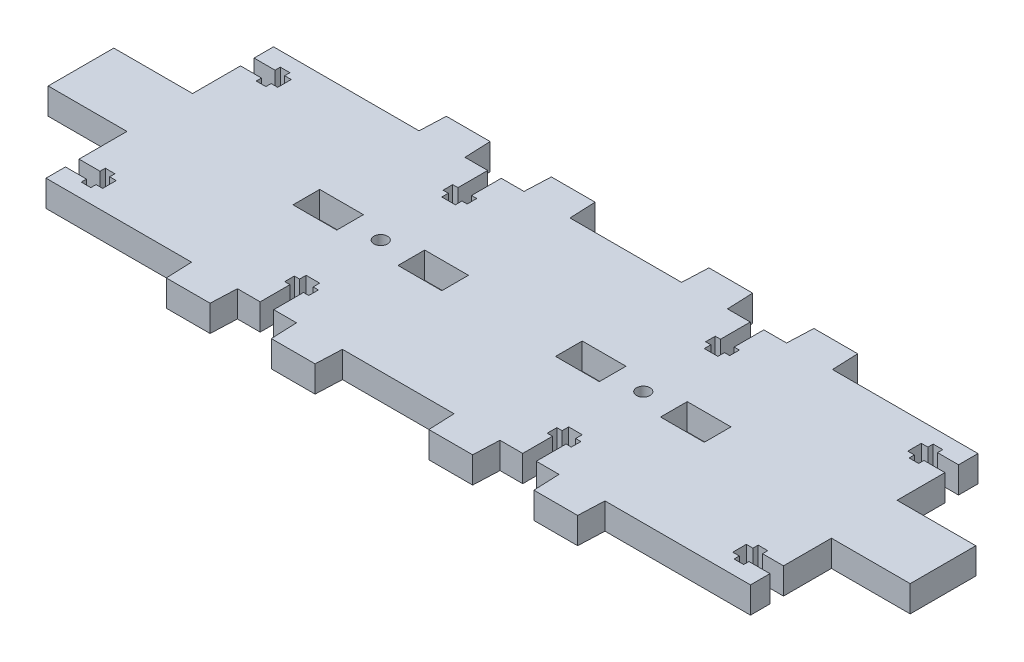
from build123d import *

# Parameters (mm, degrees)
SKETCH_1_R      = 1.55
SKETCH_1_W      = 10
SKETCH_1_H      = 6.1
EXTRUDE_1_DEPTH = 6


with BuildPart() as part:
    # Эскиз1 → Бобышка-Вытянуть1 (new body)
    with BuildSketch(Plane(origin=(0, 0, 0), x_dir=(1, 0, 0), z_dir=(0, 1, 0))):
        Polygon((10.144022003, 31.870182818), (9.894022003, 25.870182818), (-15.605977997, 25.870182818), (-15.855977997, 31.870182818), (-25.855977997, 31.870182818), (-26.105977997, 25.870182818), (-31.305977997, 25.870182818), (-31.305977997, 19.070182818), (-30.105977997, 19.070182818), (-30.105977997, 16.870182818), (-31.305977997, 16.870182818), (-31.305977997, 15.370182818), (-34.405977997, 15.370182818), (-34.405977997, 16.870182818), (-35.605977997, 16.870182818), (-35.605977997, 19.070182818), (-34.405977997, 19.070182818), (-34.405977997, 25.870182818), (-39.605977997, 25.870182818), (-39.855977997, 31.870182818), (-49.855977997, 31.870182818), (-50.105977997, 25.870182818), (-83.355977997, 25.870182818), (-83.355977997, 21.420182818), (-78.555977997, 21.420182818), (-78.555977997, 22.620182818), (-76.355977997, 22.620182818), (-76.355977997, 21.420182818), (-74.855977997, 21.420182818), (-74.855977997, 18.320182818), (-76.355977997, 18.320182818), (-76.355977997, 17.120182818), (-78.555977997, 17.120182818), (-78.555977997, 18.320182818), (-83.355977997, 18.320182818), (-83.355977997, 7.370182818), (-101.355977997, 7.370182818), (-101.355977997, -7.629817182), (-83.355977997, -7.629817182), (-83.355977997, -18.579817182), (-78.555977997, -18.579817182), (-78.555977997, -17.379817182), (-76.355977997, -17.379817182), (-76.355977997, -18.579817182), (-74.855977997, -18.579817182), (-74.855977997, -21.679817182), (-76.355977997, -21.679817182), (-76.355977997, -22.879817182), (-78.555977997, -22.879817182), (-78.555977997, -21.679817182), (-83.355977997, -21.679817182), (-83.355977997, -26.129817182), (-50.105977997, -26.129817182), (-49.855977997, -32.129817182), (-39.855977997, -32.129817182), (-39.605977997, -26.129817182), (-34.405977997, -26.129817182), (-34.405977997, -19.329817182), (-35.605977997, -19.329817182), (-35.605977997, -17.129817182), (-34.405977997, -17.129817182), (-34.405977997, -15.629817182), (-31.305977997, -15.629817182), (-31.305977997, -17.129817182), (-30.105977997, -17.129817182), (-30.105977997, -19.329817182), (-31.305977997, -19.329817182), (-31.305977997, -26.129817182), (-26.105977997, -26.129817182), (-25.855977997, -32.129817182), (-15.855977997, -32.129817182), (-15.605977997, -26.129817182), (9.894022003, -26.129817182), (10.144022003, -32.129817182), (20.144022003, -32.129817182), (20.394022003, -26.129817182), (25.594022003, -26.129817182), (25.594022003, -19.329817182), (24.394022003, -19.329817182), (24.394022003, -17.129817182), (25.594022003, -17.129817182), (25.594022003, -15.629817182), (28.694022003, -15.629817182), (28.694022003, -17.129817182), (29.894022003, -17.129817182), (29.894022003, -19.329817182), (28.694022003, -19.329817182), (28.694022003, -26.129817182), (33.894022003, -26.129817182), (34.144022003, -32.129817182), (44.144022003, -32.129817182), (44.394022003, -26.129817182), (77.644022003, -26.129817182), (77.644022003, -21.679817182), (72.844022003, -21.679817182), (72.844022003, -22.879817182), (70.644022003, -22.879817182), (70.644022003, -21.679817182), (69.144022003, -21.679817182), (69.144022003, -18.579817182), (70.644022003, -18.579817182), (70.644022003, -17.379817182), (72.844022003, -17.379817182), (72.844022003, -18.579817182), (77.644022003, -18.579817182), (77.644022003, -7.629817182), (95.644022003, -7.629817182), (95.644022003, 7.370182818), (77.644022003, 7.370182818), (77.644022003, 18.320182818), (72.844022003, 18.320182818), (72.844022003, 17.120182818), (70.644022003, 17.120182818), (70.644022003, 18.320182818), (69.144022003, 18.320182818), (69.144022003, 21.420182818), (70.644022003, 21.420182818), (70.644022003, 22.620182818), (72.844022003, 22.620182818), (72.844022003, 21.420182818), (77.644022003, 21.420182818), (77.644022003, 25.870182818), (44.394022003, 25.870182818), (44.144022003, 31.870182818), (34.144022003, 31.870182818), (33.894022003, 25.870182818), (28.694022003, 25.870182818), (28.694022003, 19.070182818), (29.894022003, 19.070182818), (29.894022003, 16.870182818), (28.694022003, 16.870182818), (28.694022003, 15.370182818), (25.594022003, 15.370182818), (25.594022003, 16.870182818), (24.394022003, 16.870182818), (24.394022003, 19.070182818), (25.594022003, 19.070182818), (25.594022003, 25.870182818), (20.394022003, 25.870182818), (20.144022003, 31.870182818), align=None)
        with Locations((-32.855977997, -0.129817182)):
            Circle(SKETCH_1_R, mode=Mode.SUBTRACT)
        with Locations((27.144022003, -0.129817182)):
            Circle(SKETCH_1_R, mode=Mode.SUBTRACT)
        with Locations((-20.855977997, -0.129817182)):
            Rectangle(SKETCH_1_W, SKETCH_1_H, mode=Mode.SUBTRACT)
        with Locations((-44.855977997, -0.129817182)):
            Rectangle(SKETCH_1_W, SKETCH_1_H, mode=Mode.SUBTRACT)
        with Locations((15.144022003, -0.129817182)):
            Rectangle(SKETCH_1_W, SKETCH_1_H, mode=Mode.SUBTRACT)
        with Locations((39.144022003, -0.129817182)):
            Rectangle(SKETCH_1_W, SKETCH_1_H, mode=Mode.SUBTRACT)
    extrude(amount=EXTRUDE_1_DEPTH)


solid = part.part
